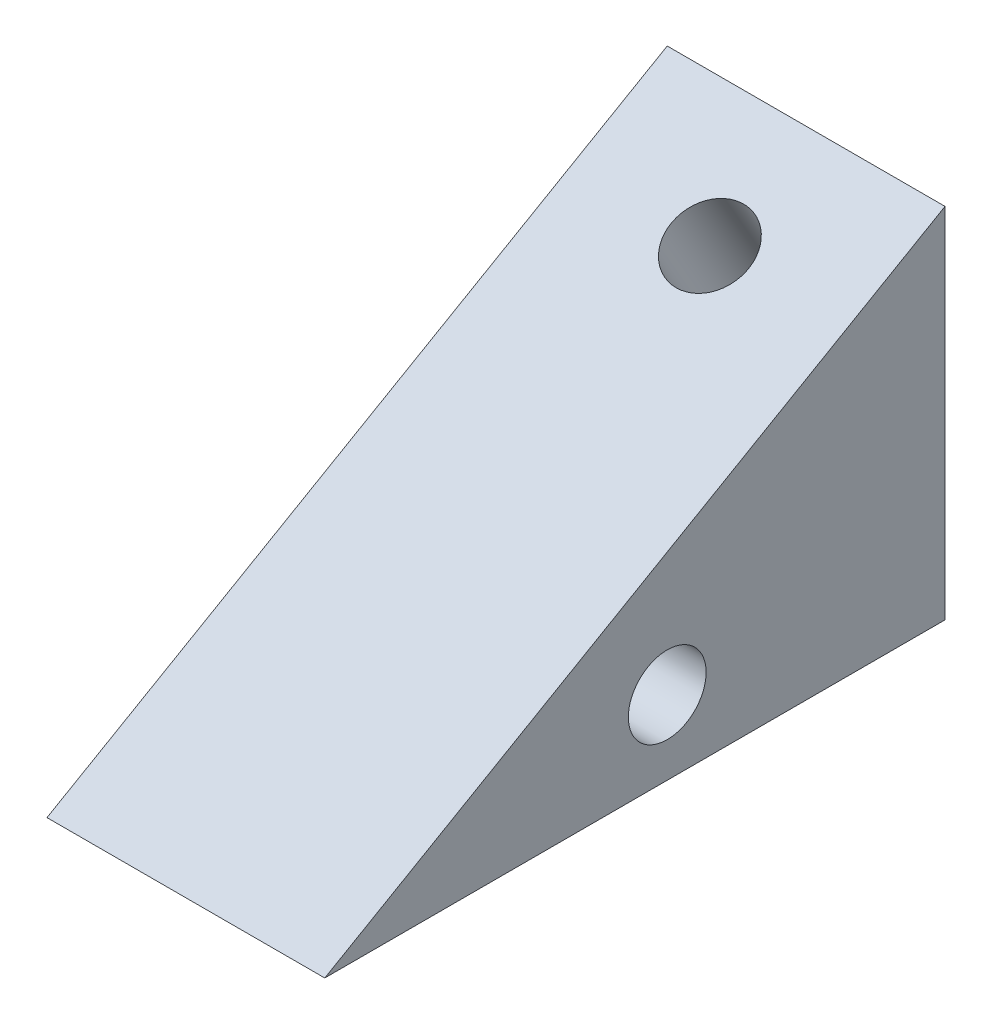
from build123d import *

# Parameters (mm, degrees)
BOSS_EXTRUDE1_DEPTH   = 15
M5X0_8_TAPPED_HOLE1_D = 4.2
M5X0_8_TAPPED_HOLE2_D = 4.2


with BuildPart() as part:
    # Sketch3 → Boss-Extrude1 (new body)
    with BuildSketch(Plane(origin=(0, 0, 0), x_dir=(0, 0, -1), z_dir=(1, 0, 0))):
        Polygon((0, 0), (-33.49045709, 0), (0, 19.335724416), align=None)
    extrude(amount=BOSS_EXTRUDE1_DEPTH)

    # M5x0.8 Tapped Hole1 (through all)
    with Locations(Plane(origin=(15, 0, 0), x_dir=(0, 0, -1), z_dir=(1, 0, 0))):
        with Locations((-15, 4)):
            Hole(M5X0_8_TAPPED_HOLE1_D / 2)

    # M5x0.8 Tapped Hole2 (through all)
    with Locations(Plane(origin=(0, 14.501793312, 8.372614273), x_dir=(1, 0, 0), z_dir=(0, 0.866025404, 0.5))):
        with Locations((7.5, 3.667862208)):
            Hole(M5X0_8_TAPPED_HOLE2_D / 2)


solid = part.part
